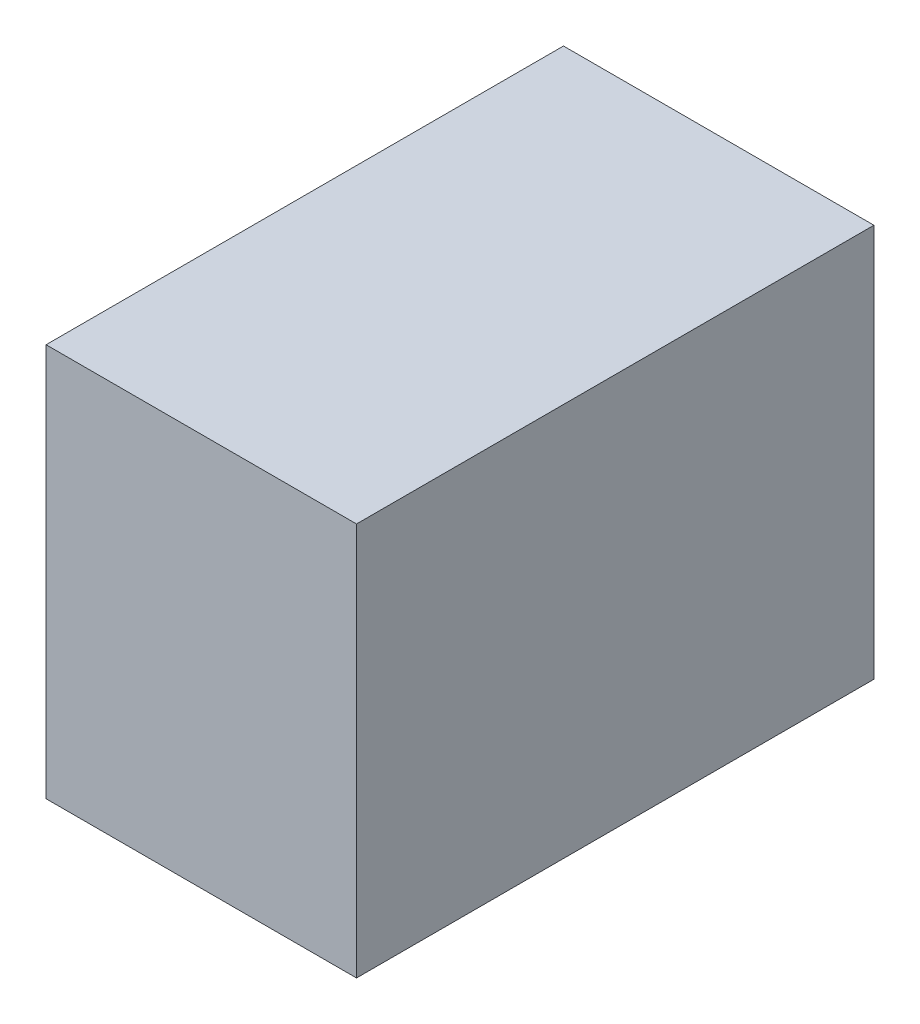
from build123d import *

# Parameters (mm, degrees)
SKETCH1_W           = 1500
SKETCH1_H           = 2500
BOSS_EXTRUDE1_DEPTH = 1900


with BuildPart() as part:
    # Sketch1 → Boss-Extrude1 (new body)
    with BuildSketch(Plane(origin=(0, 0, 0), x_dir=(1, 0, 0), z_dir=(0, 1, 0))):
        Rectangle(SKETCH1_W, SKETCH1_H)
    extrude(amount=BOSS_EXTRUDE1_DEPTH)


solid = part.part
